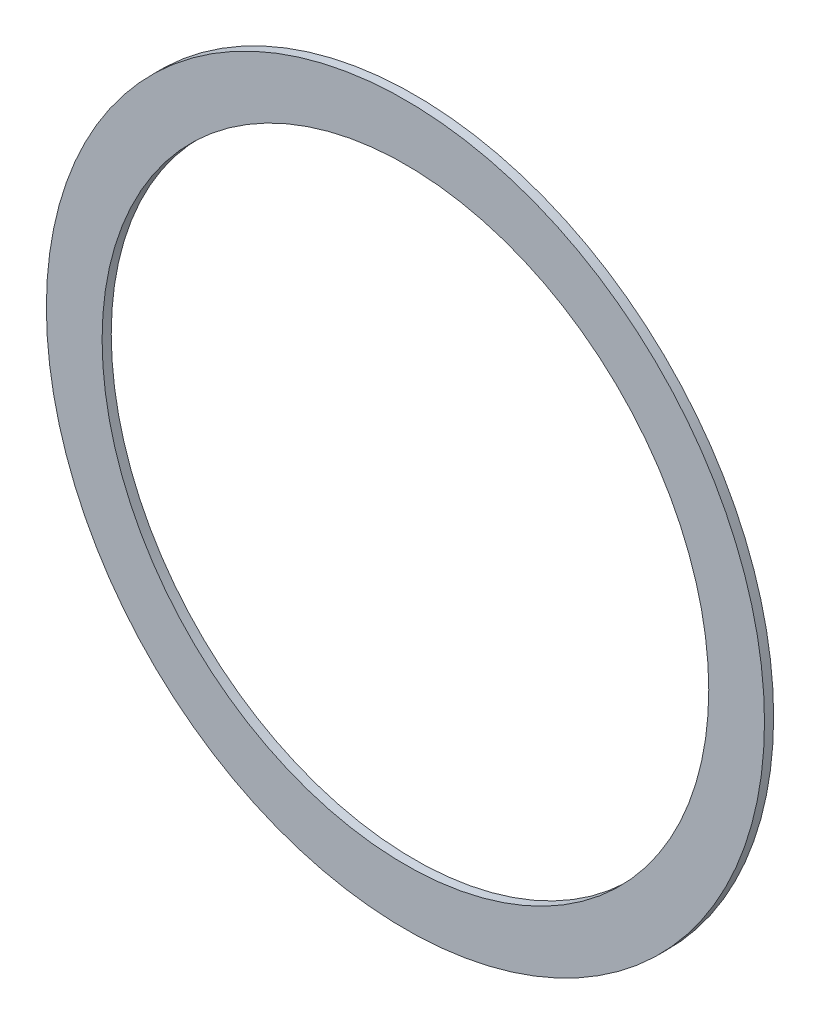
from build123d import *

# Parameters (mm, degrees)
ESQUISSE1_R        = 39.3
ESQUISSE1_R_2      = 33.2
BOSS_EXTRU_1_DEPTH = 1


with BuildPart() as part:
    # Esquisse1 → Boss.-Extru.1 (new body)
    with BuildSketch(Plane.XY):
        Circle(ESQUISSE1_R)
        Circle(ESQUISSE1_R_2, mode=Mode.SUBTRACT)
    extrude(amount=BOSS_EXTRU_1_DEPTH)


solid = part.part
